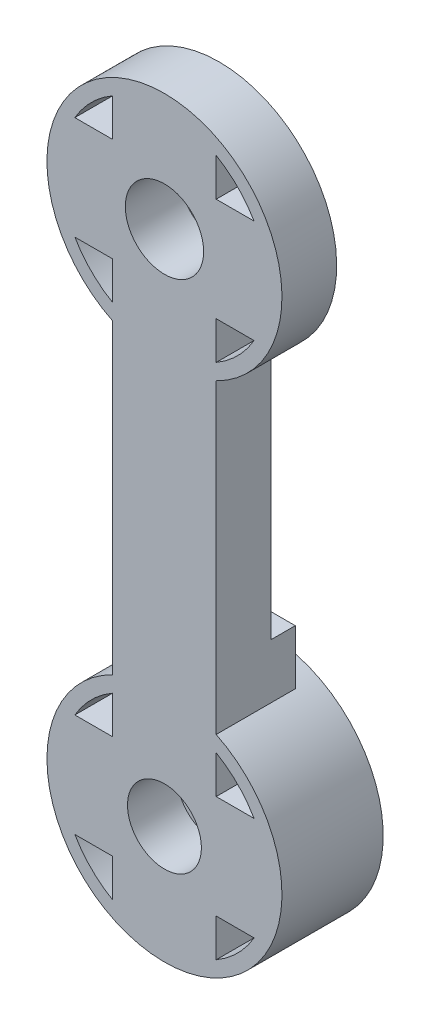
from build123d import *
from build123d.topology import SkipClean

# Parameters (mm, degrees)
SKETCH1_R               = 3.5
SKETCH1_R_2             = 1.5
BOSS_EXTRUDE4_DEPTH     = 3
BOSS_EXTRUDE5_START     = 3
SKETCH3_R               = 1.5
BOSS_EXTRUDE5_DEPTH     = 3
SKETCH4_R               = 2.5
CUT_EXTRUDE1_DEPTH      = 1.5
SKETCH5_R               = 7
CUT_EXTRUDE2_DEPTH      = 2
SKETCH6_R               = 7.95
CUT_EXTRUDE3_DEPTH      = 1
SKETCH7_R               = 2.5
CUT_EXTRUDE4_DEPTH      = 1.85
BOSS_EXTRUDE6_START     = 0.7
SKETCH8_R               = 7.95
SKETCH8_R_2             = 7
BOSS_EXTRUDE6_DEPTH     = 0.7
BOSS_EXTRUDE8_START     = 0.7
SKETCH9_R               = 7.95
SKETCH9_R_2             = 1.5
BOSS_EXTRUDE8_DEPTH     = 0.7
BOSS_EXTRUDE9_START     = 0.7
BOSS_EXTRUDE9_DEPTH     = 0.7
CUT_EXTRUDE5_DEPTH      = 45.603755447
CUT_EXTRUDE5_DEPTH_BACK = 45.603755447
SKETCH11_W              = 3
SKETCH11_H              = 15.9
SKETCH11_W_2            = 2
BOSS_EXTRUDE10_START    = 0.65
BOSS_EXTRUDE10_DEPTH    = 0.65
BOSS_EXTRUDE11_START    = 2.65
SKETCH13_R              = 1.5
BOSS_EXTRUDE11_DEPTH    = 2.65
SKETCH14_R              = 2.65
CUT_EXTRUDE6_DEPTH      = 45.138730158
BOSS_EXTRUDE12_START    = 0.5
SKETCH15_R              = 7.95
SKETCH15_R_2            = 1.5
BOSS_EXTRUDE12_DEPTH    = 0.5
BOSS_EXTRUDE13_START    = 1
BOSS_EXTRUDE13_DEPTH    = 1


with BuildPart() as part:
    # Sketch1 → Boss-Extrude4 (new body)
    # profile 1 of 34: a face of its own
    with BuildSketch(Plane.XY):
        with BuildLine():
            Line((-3.5, 3.5), (0, 3.5))
            Line((0, 3.5), (3.5, 3.5))
            Line((3.5, 3.5), (3.5, 6.062177826))
            ThreePointArc((3.5, 6.062177826), (0, 7), (-3.5, 6.062177826))
            Line((-3.5, 6.062177826), (-3.5, 3.5))
        make_face()
    # profile 2 of 34: a face of its own
    with BuildSketch(Plane.XY):
        with BuildLine():
            ThreePointArc((3.5, 6.062177826), (4.949747468, 4.949747468), (6.062177826, 3.5))
            Line((6.062177826, 3.5), (7.138101989, 3.5))
            ThreePointArc((7.138101989, 3.5), (0, 7.95), (-7.138101989, 3.5))
            Line((-7.138101989, 3.5), (-6.062177826, 3.5))
            ThreePointArc((-6.062177826, 3.5), (-4.949747468, 4.949747468), (-3.5, 6.062177826))
            ThreePointArc((-3.5, 6.062177826), (0, 7), (3.5, 6.062177826))
        make_face()
    # profile 3 of 34: a face of its own
    with BuildSketch(Plane.XY):
        with BuildLine():
            Line((3.5, -27.861898011), (3.5, -7.138101989))
            ThreePointArc((3.5, -7.138101989), (0, -7.95), (-3.5, -7.138101989))
            Line((-3.5, -7.138101989), (-3.5, -27.861898011))
            ThreePointArc((-3.5, -27.861898011), (0, -27.05), (3.5, -27.861898011))
        make_face()
    # profile 4 of 34: a face of its own
    with BuildSketch(Plane.XY):
        with BuildLine():
            Line((-6.062177826, -38.5), (-7.138101989, -38.5))
            ThreePointArc((-7.138101989, -38.5), (0, -42.95), (7.138101989, -38.5))
            Line((7.138101989, -38.5), (6.062177826, -38.5))
            ThreePointArc((6.062177826, -38.5), (4.949747468, -39.949747468), (3.5, -41.062177826))
            ThreePointArc((3.5, -41.062177826), (0, -42), (-3.5, -41.062177826))
            ThreePointArc((-3.5, -41.062177826), (-4.949747468, -39.949747468), (-6.062177826, -38.5))
        make_face()
    # profile 5 of 34: a face of its own
    with BuildSketch(Plane.XY):
        with BuildLine():
            Line((3.5, -41.062177826), (3.5, -38.5))
            Line((3.5, -38.5), (0, -38.5))
            Line((0, -38.5), (-3.5, -38.5))
            Line((-3.5, -38.5), (-3.5, -41.062177826))
            ThreePointArc((-3.5, -41.062177826), (0, -42), (3.5, -41.062177826))
        make_face()
    # profile 6 of 34: a face of its own
    with BuildSketch(Plane.XY):
        with BuildLine():
            ThreePointArc((7.95, -35), (7.744366043, -33.203532746), (7.138101989, -31.5))
            Line((7.138101989, -31.5), (6.062177826, -31.5))
            ThreePointArc((6.062177826, -31.5), (6.761480784, -33.188266684), (7, -35))
            ThreePointArc((7, -35), (6.761480784, -36.811733316), (6.062177826, -38.5))
            Line((6.062177826, -38.5), (7.138101989, -38.5))
            ThreePointArc((7.138101989, -38.5), (7.744366043, -36.796467254), (7.95, -35))
        make_face()
    # profile 7 of 34: a face of its own
    with BuildSketch(Plane.XY):
        with BuildLine():
            Line((-6.062177826, -31.5), (-7.138101989, -31.5))
            ThreePointArc((-7.138101989, -31.5), (-7.95, -35), (-7.138101989, -38.5))
            Line((-7.138101989, -38.5), (-6.062177826, -38.5))
            ThreePointArc((-6.062177826, -38.5), (-7, -35), (-6.062177826, -31.5))
        make_face()
    # profile 8 of 34: a face of its own
    with BuildSketch(Plane.XY):
        with BuildLine():
            Line((3.5, -38.5), (3.5, -35))
            ThreePointArc((3.5, -35), (2.474873734, -37.474873734), (0, -38.5))
            Line((0, -38.5), (3.5, -38.5))
        make_face()
    # profile 9 of 34: a face of its own
    with BuildSketch(Plane.XY):
        with BuildLine():
            ThreePointArc((0, -38.5), (-2.474873734, -37.474873734), (-3.5, -35))
            Line((-3.5, -35), (-3.5, -38.5))
            Line((-3.5, -38.5), (0, -38.5))
        make_face()
    # profile 10 of 34: a face of its own
    with BuildSketch(Plane.XY):
        with BuildLine():
            ThreePointArc((7.95, -35), (7.744366043, -33.203532746), (7.138101989, -31.5))
            Line((7.138101989, -31.5), (6.062177826, -31.5))
            ThreePointArc((6.062177826, -31.5), (6.761480784, -33.188266684), (7, -35))
            ThreePointArc((7, -35), (6.761480784, -36.811733316), (6.062177826, -38.5))
            Line((6.062177826, -38.5), (7.138101989, -38.5))
            ThreePointArc((7.138101989, -38.5), (7.744366043, -36.796467254), (7.95, -35))
        make_face()
    # profile 11 of 34: a face of its own
    with BuildSketch(Plane.XY):
        with BuildLine():
            Line((-6.062177826, -31.5), (-7.138101989, -31.5))
            ThreePointArc((-7.138101989, -31.5), (-7.95, -35), (-7.138101989, -38.5))
            Line((-7.138101989, -38.5), (-6.062177826, -38.5))
            ThreePointArc((-6.062177826, -38.5), (-7, -35), (-6.062177826, -31.5))
        make_face()
    # profile 12 of 34: a face of its own
    with BuildSketch(Plane.XY):
        with Locations((0, -35)):
            Circle(SKETCH1_R)
        with Locations((0, -35)):
            Circle(SKETCH1_R_2, mode=Mode.SUBTRACT)
    # profile 13 of 34: a face of its own
    with BuildSketch(Plane.XY):
        with BuildLine():
            Line((0, -31.5), (-3.5, -31.5))
            Line((-3.5, -31.5), (-3.5, -35))
            ThreePointArc((-3.5, -35), (-2.474873734, -32.525126266), (0, -31.5))
        make_face()
    # profile 14 of 34: a face of its own
    with BuildSketch(Plane.XY):
        with BuildLine():
            Line((3.5, -35), (3.5, -31.5))
            Line((3.5, -31.5), (0, -31.5))
            ThreePointArc((0, -31.5), (2.474873734, -32.525126266), (3.5, -35))
        make_face()
    # profile 15 of 34: a face of its own
    with BuildSketch(Plane.XY):
        with BuildLine():
            Line((3.5, -31.5), (3.5, -28.937822174))
            ThreePointArc((3.5, -28.937822174), (0, -28), (-3.5, -28.937822174))
            Line((-3.5, -28.937822174), (-3.5, -31.5))
            Line((-3.5, -31.5), (0, -31.5))
            Line((0, -31.5), (3.5, -31.5))
        make_face()
    # profile 16 of 34: a face of its own
    with BuildSketch(Plane.XY):
        with BuildLine():
            Line((-3.5, -28.937822174), (-3.5, -27.861898011))
            ThreePointArc((-3.5, -27.861898011), (-5.62149891, -29.37850109), (-7.138101989, -31.5))
            Line((-7.138101989, -31.5), (-6.062177826, -31.5))
            ThreePointArc((-6.062177826, -31.5), (-4.949747468, -30.050252532), (-3.5, -28.937822174))
        make_face()
    # profile 17 of 34: a face of its own
    with BuildSketch(Plane.XY):
        with BuildLine():
            ThreePointArc((7.138101989, -31.5), (5.62149891, -29.37850109), (3.5, -27.861898011))
            Line((3.5, -27.861898011), (3.5, -28.937822174))
            ThreePointArc((3.5, -28.937822174), (4.949747468, -30.050252532), (6.062177826, -31.5))
            Line((6.062177826, -31.5), (7.138101989, -31.5))
        make_face()
    # profile 18 of 34: a face of its own
    with BuildSketch(Plane.XY):
        with BuildLine():
            Line((3.5, -28.937822174), (3.5, -27.861898011))
            ThreePointArc((3.5, -27.861898011), (0, -27.05), (-3.5, -27.861898011))
            Line((-3.5, -27.861898011), (-3.5, -28.937822174))
            ThreePointArc((-3.5, -28.937822174), (0, -28), (3.5, -28.937822174))
        make_face()
    # profile 19 of 34: a face of its own
    with BuildSketch(Plane.XY):
        with BuildLine():
            Line((-3.5, -35), (-3.5, -31.5))
            Line((-3.5, -31.5), (-6.062177826, -31.5))
            ThreePointArc((-6.062177826, -31.5), (-7, -35), (-6.062177826, -38.5))
            Line((-6.062177826, -38.5), (-3.5, -38.5))
            Line((-3.5, -38.5), (-3.5, -35))
        make_face()
    # profile 20 of 34: a face of its own
    with BuildSketch(Plane.XY):
        with BuildLine():
            Line((6.062177826, -31.5), (3.5, -31.5))
            Line((3.5, -31.5), (3.5, -35))
            Line((3.5, -35), (3.5, -38.5))
            Line((3.5, -38.5), (6.062177826, -38.5))
            ThreePointArc((6.062177826, -38.5), (6.761480784, -36.811733316), (7, -35))
            ThreePointArc((7, -35), (6.761480784, -33.188266684), (6.062177826, -31.5))
        make_face()
    # profile 21 of 34: a face of its own
    with BuildSketch(Plane.XY):
        with BuildLine():
            Line((3.5, -6.062177826), (3.5, -3.5))
            Line((3.5, -3.5), (0, -3.5))
            Line((0, -3.5), (-3.5, -3.5))
            Line((-3.5, -3.5), (-3.5, -6.062177826))
            ThreePointArc((-3.5, -6.062177826), (0, -7), (3.5, -6.062177826))
        make_face()
    # profile 22 of 34: a face of its own
    with BuildSketch(Plane.XY):
        with BuildLine():
            Line((3.5, -7.138101989), (3.5, -6.062177826))
            ThreePointArc((3.5, -6.062177826), (0, -7), (-3.5, -6.062177826))
            Line((-3.5, -6.062177826), (-3.5, -7.138101989))
            ThreePointArc((-3.5, -7.138101989), (0, -7.95), (3.5, -7.138101989))
        make_face()
    # profile 23 of 34: a face of its own
    with BuildSketch(Plane.XY):
        with BuildLine():
            Line((7.138101989, -3.5), (6.062177826, -3.5))
            ThreePointArc((6.062177826, -3.5), (4.949747468, -4.949747468), (3.5, -6.062177826))
            Line((3.5, -6.062177826), (3.5, -7.138101989))
            ThreePointArc((3.5, -7.138101989), (5.62149891, -5.62149891), (7.138101989, -3.5))
        make_face()
    # profile 24 of 34: a face of its own
    with BuildSketch(Plane.XY):
        with BuildLine():
            Line((7.138101989, 3.5), (6.062177826, 3.5))
            ThreePointArc((6.062177826, 3.5), (6.761480784, 1.811733316), (7, 0))
            ThreePointArc((7, 0), (6.761480784, -1.811733316), (6.062177826, -3.5))
            Line((6.062177826, -3.5), (7.138101989, -3.5))
            ThreePointArc((7.138101989, -3.5), (7.744366043, -1.796467254), (7.95, 0))
            ThreePointArc((7.95, 0), (7.744366043, 1.796467254), (7.138101989, 3.5))
        make_face()
    # profile 25 of 34: a face of its own
    with BuildSketch(Plane.XY):
        with BuildLine():
            Line((7.138101989, 3.5), (6.062177826, 3.5))
            ThreePointArc((6.062177826, 3.5), (6.761480784, 1.811733316), (7, 0))
            ThreePointArc((7, 0), (6.761480784, -1.811733316), (6.062177826, -3.5))
            Line((6.062177826, -3.5), (7.138101989, -3.5))
            ThreePointArc((7.138101989, -3.5), (7.744366043, -1.796467254), (7.95, 0))
            ThreePointArc((7.95, 0), (7.744366043, 1.796467254), (7.138101989, 3.5))
        make_face()
    # profile 26 of 34: a face of its own
    with BuildSketch(Plane.XY):
        with BuildLine():
            ThreePointArc((-6.062177826, -3.5), (-7, 0), (-6.062177826, 3.5))
            Line((-6.062177826, 3.5), (-7.138101989, 3.5))
            ThreePointArc((-7.138101989, 3.5), (-7.95, 0), (-7.138101989, -3.5))
            Line((-7.138101989, -3.5), (-6.062177826, -3.5))
        make_face()
    # profile 27 of 34: a face of its own
    with BuildSketch(Plane.XY):
        with BuildLine():
            ThreePointArc((-3.5, -6.062177826), (-4.949747468, -4.949747468), (-6.062177826, -3.5))
            Line((-6.062177826, -3.5), (-7.138101989, -3.5))
            ThreePointArc((-7.138101989, -3.5), (-5.62149891, -5.62149891), (-3.5, -7.138101989))
            Line((-3.5, -7.138101989), (-3.5, -6.062177826))
        make_face()
    # profile 28 of 34: a face of its own
    with BuildSketch(Plane.XY):
        with BuildLine():
            Line((-3.5, 0), (-3.5, 3.5))
            Line((-3.5, 3.5), (-6.062177826, 3.5))
            ThreePointArc((-6.062177826, 3.5), (-7, 0), (-6.062177826, -3.5))
            Line((-6.062177826, -3.5), (-3.5, -3.5))
            Line((-3.5, -3.5), (-3.5, 0))
        make_face()
    # profile 29 of 34: a face of its own
    with BuildSketch(Plane.XY):
        with BuildLine():
            Line((6.062177826, 3.5), (3.5, 3.5))
            Line((3.5, 3.5), (3.5, 0))
            Line((3.5, 0), (3.5, -3.5))
            Line((3.5, -3.5), (6.062177826, -3.5))
            ThreePointArc((6.062177826, -3.5), (6.761480784, -1.811733316), (7, 0))
            ThreePointArc((7, 0), (6.761480784, 1.811733316), (6.062177826, 3.5))
        make_face()
    # profile 30 of 34: a face of its own
    with BuildSketch(Plane.XY):
        with BuildLine():
            Line((3.5, -3.5), (3.5, 0))
            ThreePointArc((3.5, 0), (2.474873734, -2.474873734), (0, -3.5))
            Line((0, -3.5), (3.5, -3.5))
        make_face()
    # profile 31 of 34: a face of its own
    with BuildSketch(Plane.XY):
        Circle(SKETCH1_R)
        Circle(SKETCH1_R_2, mode=Mode.SUBTRACT)
    # profile 32 of 34: a face of its own
    with BuildSketch(Plane.XY):
        with BuildLine():
            ThreePointArc((0, -3.5), (-2.474873734, -2.474873734), (-3.5, 0))
            Line((-3.5, 0), (-3.5, -3.5))
            Line((-3.5, -3.5), (0, -3.5))
        make_face()
    # profile 33 of 34: a face of its own
    with BuildSketch(Plane.XY):
        with BuildLine():
            ThreePointArc((-3.5, 0), (-2.474873734, 2.474873734), (0, 3.5))
            Line((0, 3.5), (-3.5, 3.5))
            Line((-3.5, 3.5), (-3.5, 0))
        make_face()
    # profile 34 of 34: a face of its own
    with BuildSketch(Plane.XY):
        with BuildLine():
            Line((3.5, 3.5), (0, 3.5))
            ThreePointArc((0, 3.5), (2.474873734, 2.474873734), (3.5, 0))
            Line((3.5, 0), (3.5, 3.5))
        make_face()
    extrude(amount=BOSS_EXTRUDE4_DEPTH)

    # Sketch3 → Boss-Extrude5 (add)
    # profile 1 of 4: a face of its own
    with SkipClean():  # the faces are left unmerged after this step: merging them gives an invalid solid
        with BuildSketch(Plane(origin=(0, 0, 0), x_dir=(-1, 0, 0), z_dir=(0, 0, -1)).offset(BOSS_EXTRUDE5_START)):
            with BuildLine():
                ThreePointArc((3.5, -7.138101989), (6.746387922, -4.205799567), (7.95, 0))
                ThreePointArc((7.95, 0), (-4.205799567, 6.746387922), (-3.5, -7.138101989))
                ThreePointArc((-3.5, -7.138101989), (0, -7.95), (3.5, -7.138101989))
            make_face()
            with BuildLine():
                ThreePointArc((-6.062177826, 3.5), (-4.949747468, 4.949747468), (-3.5, 6.062177826))
                ThreePointArc((-3.5, 6.062177826), (0, 7), (3.5, 6.062177826))
                ThreePointArc((3.5, 6.062177826), (4.949747468, 4.949747468), (6.062177826, 3.5))
                ThreePointArc((6.062177826, 3.5), (6.761480784, 1.811733316), (7, 0))
                ThreePointArc((7, 0), (6.761480784, -1.811733316), (6.062177826, -3.5))
                ThreePointArc((6.062177826, -3.5), (4.949747468, -4.949747468), (3.5, -6.062177826))
                ThreePointArc((3.5, -6.062177826), (0, -7), (-3.5, -6.062177826))
                ThreePointArc((-3.5, -6.062177826), (-4.949747468, -4.949747468), (-6.062177826, -3.5))
                ThreePointArc((-6.062177826, -3.5), (-7, 0), (-6.062177826, 3.5))
            make_face(mode=Mode.SUBTRACT)
        # profile 2 of 4: a face of its own
        with BuildSketch(Plane(origin=(0, 0, 0), x_dir=(-1, 0, 0), z_dir=(0, 0, -1)).offset(BOSS_EXTRUDE5_START)):
            with BuildLine():
                ThreePointArc((3.5, 6.062177826), (0, 7), (-3.5, 6.062177826))
                Line((-3.5, 6.062177826), (-3.5, 3.5))
                Line((-3.5, 3.5), (-6.062177826, 3.5))
                ThreePointArc((-6.062177826, 3.5), (-7, 0), (-6.062177826, -3.5))
                Line((-6.062177826, -3.5), (-3.5, -3.5))
                Line((-3.5, -3.5), (-3.5, -6.062177826))
                ThreePointArc((-3.5, -6.062177826), (0, -7), (3.5, -6.062177826))
                Line((3.5, -6.062177826), (3.5, -3.5))
                Line((3.5, -3.5), (6.062177826, -3.5))
                ThreePointArc((6.062177826, -3.5), (6.761480784, -1.811733316), (7, 0))
                ThreePointArc((7, 0), (6.761480784, 1.811733316), (6.062177826, 3.5))
                Line((6.062177826, 3.5), (3.5, 3.5))
                Line((3.5, 3.5), (3.5, 6.062177826))
            make_face()
            Circle(SKETCH3_R, mode=Mode.SUBTRACT)
        # profile 3 of 4: a face of its own
        with BuildSketch(Plane(origin=(0, 0, 0), x_dir=(-1, 0, 0), z_dir=(0, 0, -1)).offset(BOSS_EXTRUDE5_START)):
            with BuildLine():
                ThreePointArc((-3.5, -27.861898011), (-4.205799567, -41.746387922), (7.95, -35))
                ThreePointArc((7.95, -35), (6.746387922, -30.794200433), (3.5, -27.861898011))
                ThreePointArc((3.5, -27.861898011), (0, -27.05), (-3.5, -27.861898011))
            make_face()
            with BuildLine():
                ThreePointArc((6.062177826, -38.5), (4.949747468, -39.949747468), (3.5, -41.062177826))
                ThreePointArc((3.5, -41.062177826), (0, -42), (-3.5, -41.062177826))
                ThreePointArc((-3.5, -41.062177826), (-4.949747468, -39.949747468), (-6.062177826, -38.5))
                ThreePointArc((-6.062177826, -38.5), (-7, -35), (-6.062177826, -31.5))
                ThreePointArc((-6.062177826, -31.5), (-4.949747468, -30.050252532), (-3.5, -28.937822174))
                ThreePointArc((-3.5, -28.937822174), (0, -28), (3.5, -28.937822174))
                ThreePointArc((3.5, -28.937822174), (4.949747468, -30.050252532), (6.062177826, -31.5))
                ThreePointArc((6.062177826, -31.5), (6.761480784, -33.188266684), (7, -35))
                ThreePointArc((7, -35), (6.761480784, -36.811733316), (6.062177826, -38.5))
            make_face(mode=Mode.SUBTRACT)
        # profile 4 of 4: a face of its own
        with BuildSketch(Plane(origin=(0, 0, 0), x_dir=(-1, 0, 0), z_dir=(0, 0, -1)).offset(BOSS_EXTRUDE5_START)):
            with BuildLine():
                ThreePointArc((-3.5, -41.062177826), (0, -42), (3.5, -41.062177826))
                Line((3.5, -41.062177826), (3.5, -38.5))
                Line((3.5, -38.5), (6.062177826, -38.5))
                ThreePointArc((6.062177826, -38.5), (6.761480784, -36.811733316), (7, -35))
                ThreePointArc((7, -35), (6.761480784, -33.188266684), (6.062177826, -31.5))
                Line((6.062177826, -31.5), (3.5, -31.5))
                Line((3.5, -31.5), (3.5, -28.937822174))
                ThreePointArc((3.5, -28.937822174), (0, -28), (-3.5, -28.937822174))
                Line((-3.5, -28.937822174), (-3.5, -31.5))
                Line((-3.5, -31.5), (-6.062177826, -31.5))
                ThreePointArc((-6.062177826, -31.5), (-7, -35), (-6.062177826, -38.5))
                Line((-6.062177826, -38.5), (-3.5, -38.5))
                Line((-3.5, -38.5), (-3.5, -41.062177826))
            make_face()
            with Locations((0, -35)):
                Circle(SKETCH3_R, mode=Mode.SUBTRACT)
        extrude(amount=-BOSS_EXTRUDE5_DEPTH)

    # Sketch4 → Cut-Extrude1 (cut)
    with SkipClean():  # the faces are left unmerged after this step: merging them gives an invalid solid
        with BuildSketch(Plane.XY.offset(3)):
            with Locations((0, -35)):
                Circle(SKETCH4_R)
            with Locations(Location((0, 0, 0), (0, 0, 180))):
                Circle(SKETCH4_R)
        extrude(amount=-CUT_EXTRUDE1_DEPTH, mode=Mode.SUBTRACT)

    # Sketch5 → Cut-Extrude2 (cut)
    with SkipClean():  # the faces are left unmerged after this step: merging them gives an invalid solid
        with BuildSketch(Plane(origin=(0, 0, -3), x_dir=(-1, 0, 0), z_dir=(0, 0, -1))):
            Circle(SKETCH5_R)
        extrude(amount=-CUT_EXTRUDE2_DEPTH, mode=Mode.SUBTRACT)

    # Sketch6 → Cut-Extrude3 (cut)
    with SkipClean():  # the faces are left unmerged after this step: merging them gives an invalid solid
        with BuildSketch(Plane(origin=(0, 0, -3), x_dir=(-1, 0, 0), z_dir=(0, 0, -1))):
            with Locations((0, -35)):
                Circle(SKETCH6_R)
        extrude(amount=-CUT_EXTRUDE3_DEPTH, mode=Mode.SUBTRACT)

    # Sketch7 → Cut-Extrude4 (cut)
    with SkipClean():  # the faces are left unmerged after this step: merging them gives an invalid solid
        with BuildSketch(Plane.XY.offset(1.5)):
            with Locations((0, -35)):
                Circle(SKETCH7_R)
        extrude(amount=-CUT_EXTRUDE4_DEPTH, mode=Mode.SUBTRACT)

    # Sketch8 → Boss-Extrude6 (add)
    with SkipClean():  # the faces are left unmerged after this step: merging them gives an invalid solid
        with BuildSketch(Plane(origin=(0, 0, -3), x_dir=(-1, 0, 0), z_dir=(0, 0, -1)).offset(BOSS_EXTRUDE6_START)):
            Circle(SKETCH8_R)
            Circle(SKETCH8_R_2, mode=Mode.SUBTRACT)
        extrude(amount=-BOSS_EXTRUDE6_DEPTH)

    # Sketch9 → Boss-Extrude8 (add)
    # profile 1 of 2: a face of its own
    with SkipClean():  # the faces are left unmerged after this step: merging them gives an invalid solid
        with BuildSketch(Plane(origin=(0, 0, -2), x_dir=(-1, 0, 0), z_dir=(0, 0, -1)).offset(BOSS_EXTRUDE8_START)):
            with Locations((0, -35)):
                Circle(SKETCH9_R)
            with BuildLine():
                ThreePointArc((-6.062177826, -31.5), (-4.949747468, -30.050252532), (-3.5, -28.937822174))
                ThreePointArc((-3.5, -28.937822174), (0, -28), (3.5, -28.937822174))
                ThreePointArc((3.5, -28.937822174), (4.949747468, -30.050252532), (6.062177826, -31.5))
                ThreePointArc((6.062177826, -31.5), (6.761480784, -33.188266684), (7, -35))
                ThreePointArc((7, -35), (6.761480784, -36.811733316), (6.062177826, -38.5))
                ThreePointArc((6.062177826, -38.5), (4.949747468, -39.949747468), (3.5, -41.062177826))
                ThreePointArc((3.5, -41.062177826), (0, -42), (-3.5, -41.062177826))
                ThreePointArc((-3.5, -41.062177826), (-4.949747468, -39.949747468), (-6.062177826, -38.5))
                ThreePointArc((-6.062177826, -38.5), (-7, -35), (-6.062177826, -31.5))
            make_face(mode=Mode.SUBTRACT)
        # profile 2 of 2: a face of its own
        with BuildSketch(Plane(origin=(0, 0, -2), x_dir=(-1, 0, 0), z_dir=(0, 0, -1)).offset(BOSS_EXTRUDE8_START)):
            with BuildLine():
                ThreePointArc((3.5, -28.937822174), (0, -28), (-3.5, -28.937822174))
                Line((-3.5, -28.937822174), (-3.5, -31.5))
                Line((-3.5, -31.5), (-6.062177826, -31.5))
                ThreePointArc((-6.062177826, -31.5), (-7, -35), (-6.062177826, -38.5))
                Line((-6.062177826, -38.5), (-3.5, -38.5))
                Line((-3.5, -38.5), (-3.5, -41.062177826))
                ThreePointArc((-3.5, -41.062177826), (0, -42), (3.5, -41.062177826))
                Line((3.5, -41.062177826), (3.5, -38.5))
                Line((3.5, -38.5), (6.062177826, -38.5))
                ThreePointArc((6.062177826, -38.5), (6.761480784, -36.811733316), (7, -35))
                ThreePointArc((7, -35), (6.761480784, -33.188266684), (6.062177826, -31.5))
                Line((6.062177826, -31.5), (3.5, -31.5))
                Line((3.5, -31.5), (3.5, -28.937822174))
            make_face()
            with Locations((0, -35)):
                Circle(SKETCH9_R_2, mode=Mode.SUBTRACT)
        extrude(amount=-BOSS_EXTRUDE8_DEPTH)

    # Sketch10 → Boss-Extrude9 (add)
    with SkipClean():  # the faces are left unmerged after this step: merging them gives an invalid solid
        with BuildSketch(Plane(origin=(0, 0, 0), x_dir=(-1, 0, 0), z_dir=(0, 0, -1)).offset(BOSS_EXTRUDE9_START)):
            with BuildLine():
                ThreePointArc((3.5, -7.138101989), (0, -7.95), (-3.5, -7.138101989))
                Line((-3.5, -7.138101989), (-3.5, -27.861898011))
                ThreePointArc((-3.5, -27.861898011), (0, -27.05), (3.5, -27.861898011))
                Line((3.5, -27.861898011), (3.5, -7.138101989))
            make_face()
        extrude(amount=-BOSS_EXTRUDE9_DEPTH)

    # Sketch11 → Cut-Extrude5 (cut, two sides: drawn at the far end of the back side and taken through both)
    with SkipClean():  # the faces are left unmerged after this step: merging them gives an invalid solid
        with BuildSketch(Plane(origin=(3.5, 0, 0), x_dir=(0, 0, -1), z_dir=(1, 0, 0)).offset(-CUT_EXTRUDE5_DEPTH_BACK)):
            with Locations((2.2, 0)):
                Rectangle(SKETCH11_W, SKETCH11_H)
            with Locations((1.7, -35)):
                Rectangle(SKETCH11_W_2, SKETCH11_H)
        extrude(amount=CUT_EXTRUDE5_DEPTH + CUT_EXTRUDE5_DEPTH_BACK, mode=Mode.SUBTRACT)

    # Sketch12 → Boss-Extrude10 (add)
    with SkipClean():  # the faces are left unmerged after this step: merging them gives an invalid solid
        with BuildSketch(Plane(origin=(0, 0, -0.7), x_dir=(-1, 0, 0), z_dir=(0, 0, -1)).offset(BOSS_EXTRUDE10_START)):
            with BuildLine():
                Line((-3.5, -24.161898011), (-3.5, -27.861898011))
                ThreePointArc((-3.5, -27.861898011), (0, -27.05), (3.5, -27.861898011))
                Line((3.5, -27.861898011), (3.5, -24.161898011))
                Line((3.5, -24.161898011), (-3.5, -24.161898011))
            make_face()
        extrude(amount=-BOSS_EXTRUDE10_DEPTH)

    # Sketch13 → Boss-Extrude11 (add)
    # profile 1 of 2: a face of its own
    with SkipClean():  # the faces are left unmerged after this step: merging them gives an invalid solid
        with BuildSketch(Plane(origin=(0, 0, -0.7), x_dir=(-1, 0, 0), z_dir=(0, 0, -1)).offset(BOSS_EXTRUDE11_START)):
            with BuildLine():
                ThreePointArc((-3.5, -27.861898011), (-4.205799567, -41.746387922), (7.95, -35))
                ThreePointArc((7.95, -35), (6.746387922, -30.794200433), (3.5, -27.861898011))
                ThreePointArc((3.5, -27.861898011), (0, -27.05), (-3.5, -27.861898011))
            make_face()
            with BuildLine():
                ThreePointArc((-6.062177826, -38.5), (-7, -35), (-6.062177826, -31.5))
                ThreePointArc((-6.062177826, -31.5), (-4.949747468, -30.050252532), (-3.5, -28.937822174))
                ThreePointArc((-3.5, -28.937822174), (0, -28), (3.5, -28.937822174))
                ThreePointArc((3.5, -28.937822174), (4.949747468, -30.050252532), (6.062177826, -31.5))
                ThreePointArc((6.062177826, -31.5), (6.761480784, -33.188266684), (7, -35))
                ThreePointArc((7, -35), (6.761480784, -36.811733316), (6.062177826, -38.5))
                ThreePointArc((6.062177826, -38.5), (4.949747468, -39.949747468), (3.5, -41.062177826))
                ThreePointArc((3.5, -41.062177826), (0, -42), (-3.5, -41.062177826))
                ThreePointArc((-3.5, -41.062177826), (-4.949747468, -39.949747468), (-6.062177826, -38.5))
            make_face(mode=Mode.SUBTRACT)
        # profile 2 of 2: a face of its own
        with BuildSketch(Plane(origin=(0, 0, -0.7), x_dir=(-1, 0, 0), z_dir=(0, 0, -1)).offset(BOSS_EXTRUDE11_START)):
            with BuildLine():
                Line((-3.5, -31.5), (-6.062177826, -31.5))
                ThreePointArc((-6.062177826, -31.5), (-7, -35), (-6.062177826, -38.5))
                Line((-6.062177826, -38.5), (-3.5, -38.5))
                Line((-3.5, -38.5), (-3.5, -41.062177826))
                ThreePointArc((-3.5, -41.062177826), (0, -42), (3.5, -41.062177826))
                Line((3.5, -41.062177826), (3.5, -38.5))
                Line((3.5, -38.5), (6.062177826, -38.5))
                ThreePointArc((6.062177826, -38.5), (6.761480784, -36.811733316), (7, -35))
                ThreePointArc((7, -35), (6.761480784, -33.188266684), (6.062177826, -31.5))
                Line((6.062177826, -31.5), (3.5, -31.5))
                Line((3.5, -31.5), (3.5, -28.937822174))
                ThreePointArc((3.5, -28.937822174), (0, -28), (-3.5, -28.937822174))
                Line((-3.5, -28.937822174), (-3.5, -31.5))
            make_face()
            with Locations((0, -35)):
                Circle(SKETCH13_R, mode=Mode.SUBTRACT)
        extrude(amount=-BOSS_EXTRUDE11_DEPTH)

    # Sketch14 → Cut-Extrude6 (cut, through all)
    with SkipClean():  # the faces are left unmerged after this step: merging them gives an invalid solid
        with BuildSketch(Plane.XY.offset(3)):
            Circle(SKETCH14_R)
        extrude(amount=-CUT_EXTRUDE6_DEPTH, mode=Mode.SUBTRACT)

    # Sketch15 → Boss-Extrude12 (add)
    with SkipClean():  # the faces are left unmerged after this step: merging them gives an invalid solid
        with BuildSketch(Plane(origin=(0, 0, -3.35), x_dir=(-1, 0, 0), z_dir=(0, 0, -1)).offset(BOSS_EXTRUDE12_START)):
            with Locations((0, -35)):
                Circle(SKETCH15_R)
            with Locations((0, -35)):
                Circle(SKETCH15_R_2, mode=Mode.SUBTRACT)
            with BuildLine():
                Line((3.5, -41.062177826), (3.5, -38.5))
                Line((3.5, -38.5), (6.062177826, -38.5))
                ThreePointArc((6.062177826, -38.5), (4.949747468, -39.949747468), (3.5, -41.062177826))
            make_face(mode=Mode.SUBTRACT)
            with BuildLine():
                Line((-3.5, -38.5), (-3.5, -41.062177826))
                ThreePointArc((-3.5, -41.062177826), (-4.949747468, -39.949747468), (-6.062177826, -38.5))
                Line((-6.062177826, -38.5), (-3.5, -38.5))
            make_face(mode=Mode.SUBTRACT)
            with BuildLine():
                Line((-3.5, -31.5), (-6.062177826, -31.5))
                ThreePointArc((-6.062177826, -31.5), (-4.949747468, -30.050252532), (-3.5, -28.937822174))
                Line((-3.5, -28.937822174), (-3.5, -31.5))
            make_face(mode=Mode.SUBTRACT)
            with BuildLine():
                Line((3.5, -31.5), (3.5, -28.937822174))
                ThreePointArc((3.5, -28.937822174), (4.949747468, -30.050252532), (6.062177826, -31.5))
                Line((6.062177826, -31.5), (3.5, -31.5))
            make_face(mode=Mode.SUBTRACT)
        extrude(amount=-BOSS_EXTRUDE12_DEPTH)

    # Sketch17 → Boss-Extrude13 (add)
    with SkipClean():  # the faces are left unmerged after this step: merging them gives an invalid solid
        with BuildSketch(Plane(origin=(0, 0, -1.35), x_dir=(-1, 0, 0), z_dir=(0, 0, -1)).offset(BOSS_EXTRUDE13_START)):
            with BuildLine():
                Line((-3.5, -24.161898011), (-3.5, -27.861898011))
                ThreePointArc((-3.5, -27.861898011), (0, -27.05), (3.5, -27.861898011))
                Line((3.5, -27.861898011), (3.5, -24.161898011))
                Line((3.5, -24.161898011), (-3.5, -24.161898011))
            make_face()
        extrude(amount=-BOSS_EXTRUDE13_DEPTH)


solid = part.part
